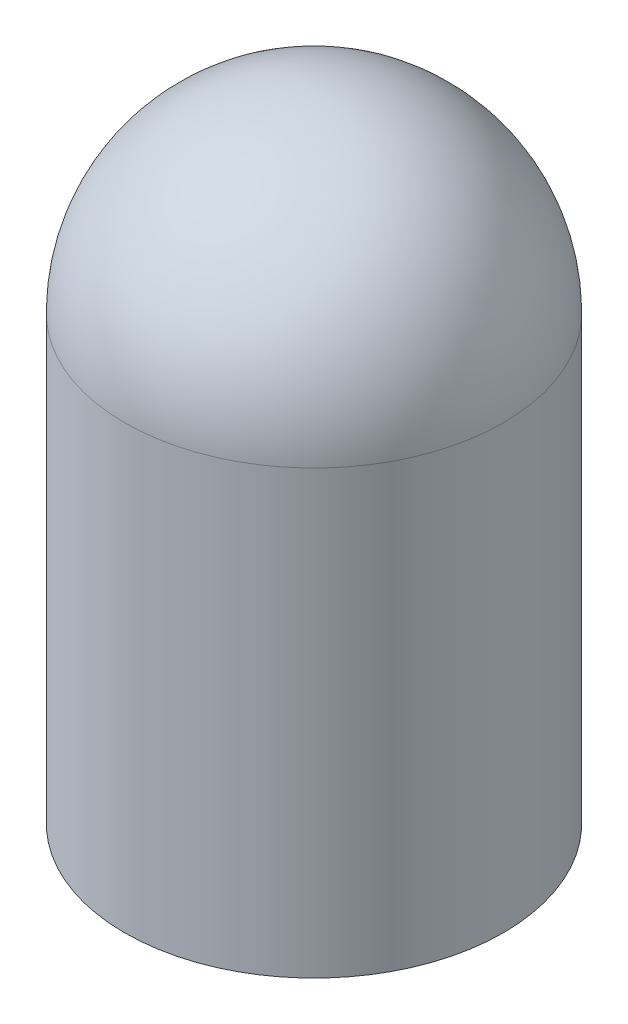
from build123d import *


with BuildPart() as part:
    # Sketch2 → Revolve1 (revolve)
    with BuildSketch(Plane.XY):
        with BuildLine():
            Line((30, 70), (30, 0))
            Line((30, 0), (0, 0))
            Line((0, 0), (0, 100))
            ThreePointArc((0, 100), (21.213203436, 91.213203436), (30, 70))
        make_face()
    revolve(axis=Axis((0, 100, 0), (0, -1, 0)))


solid = part.part
